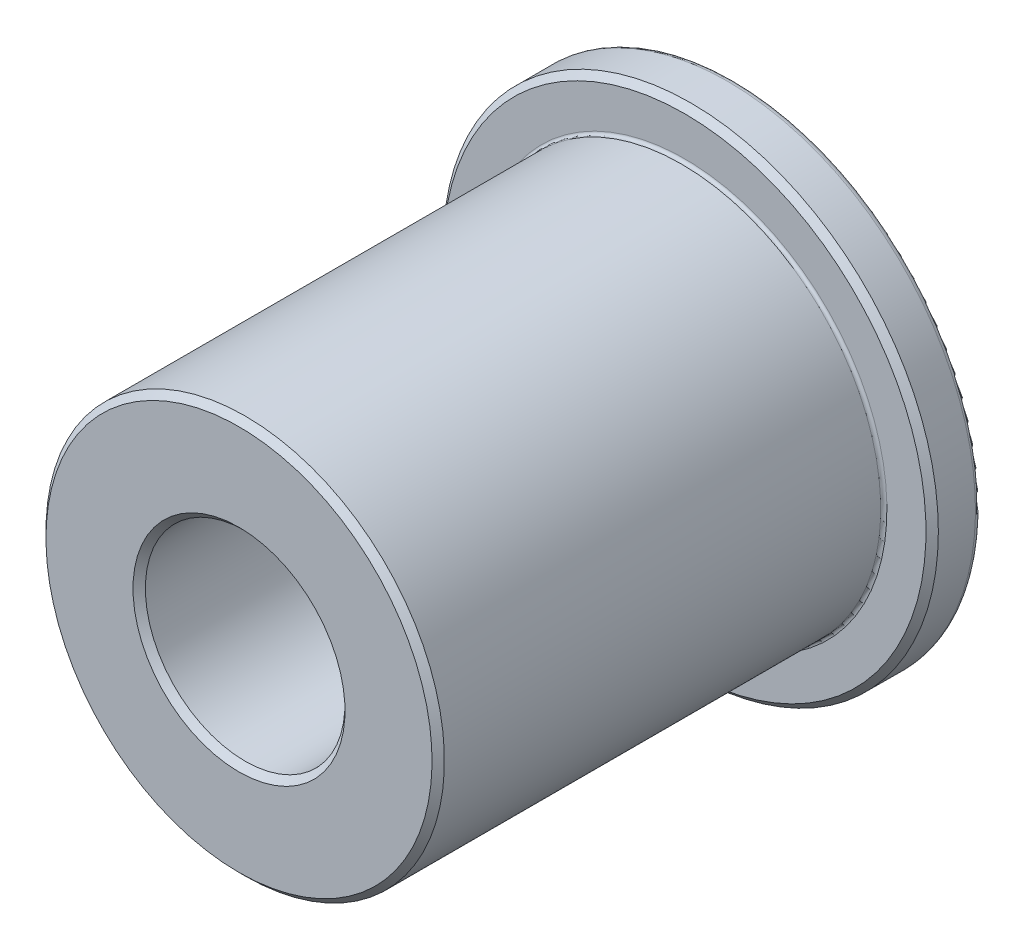
from build123d import *

# Parameters (mm, degrees)
CHAMFER1_SIZE = 0.1984375
FILLET1_R     = 0.1984375
FILLET2_R     = 0.09921875


with BuildPart() as part:
    # Sketch3 → Revolve1 (revolve)
    with BuildSketch(Plane(origin=(0, 0, 0), x_dir=(0, 0, -1), z_dir=(1, 0, 0))):
        Polygon((7.9375, 7.9375), (6.35, 7.9375), (6.35, 6.3881), (-7.9375, 6.3881), (-7.9375, 3.2004), (7.9375, 3.2004), align=None)
    revolve(axis=Axis((0, 0, -7.9375), (0, 0, 1)))

    # Chamfer1
    chamfer1_edges = [part.edges().sort_by_distance(p)[0] for p in [
        (0, -3.2004, 7.9375),
        (0, -6.3881, 7.9375),
        (0, -7.9375, -6.35),
    ]]
    chamfer(chamfer1_edges, length=CHAMFER1_SIZE)

    # Fillet1
    fillet1_edges = [part.edges().sort_by_distance(p)[0] for p in [
        (0, -7.9375, -7.9375),
    ]]
    fillet(fillet1_edges, radius=FILLET1_R)

    # Fillet2
    fillet2_edges = [part.edges().sort_by_distance(p)[0] for p in [
        (0, -6.3881, -6.35),
    ]]
    fillet(fillet2_edges, radius=FILLET2_R)


solid = part.part
